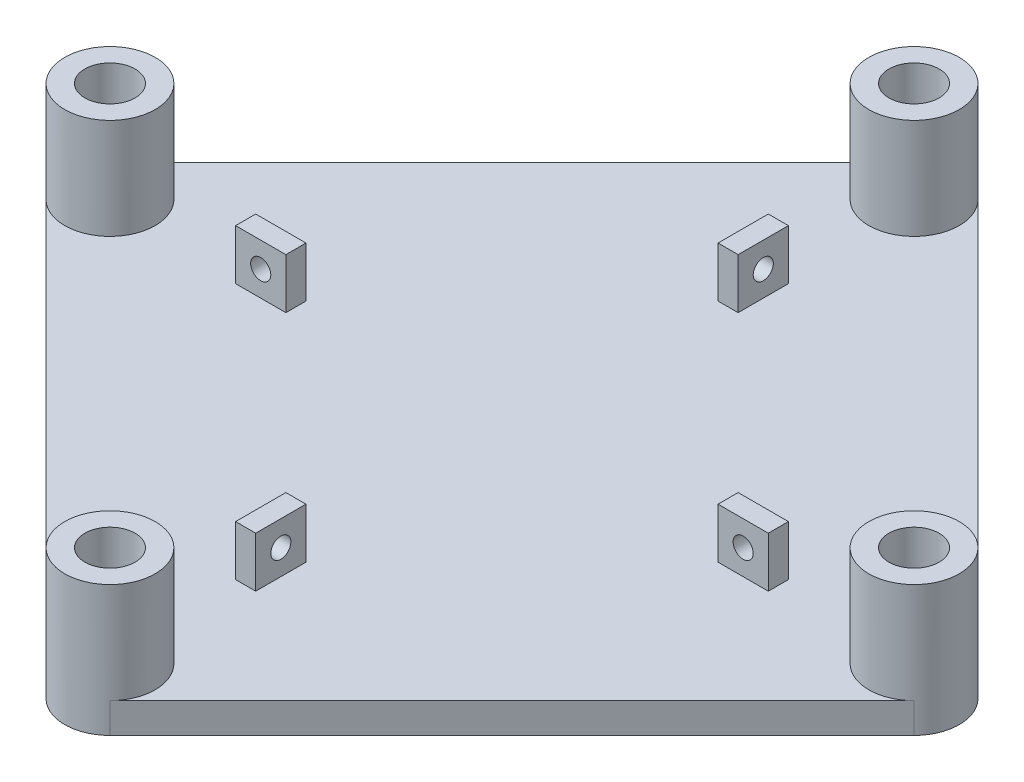
from build123d import *

# Parameters (mm, degrees)
SKETCH1_W           = 100
SKETCH1_H           = 100
BOSS_EXTRUDE1_DEPTH = 3
SKETCH2_R           = 4.5
SKETCH2_R_2         = 2.5
BOSS_EXTRUDE2_DEPTH = 10
SKETCH3_W           = 4.999999906
SKETCH3_H           = 2
SKETCH3_W_2         = 2
SKETCH3_H_2         = 4.999999906
BOSS_EXTRUDE3_DEPTH = 5
CUT_EXTRUDE1_REACH  = 74.595
SKETCH4_R           = 1
CUT_EXTRUDE2_REACH  = 74.595
SKETCH5_R           = 1
CUT_EXTRUDE3_REACH  = 74.595
SKETCH7_R           = 1
CUT_EXTRUDE4_REACH  = 74.595
SKETCH8_R           = 1
SKETCH9_OUTSIDE_W   = 130.404
SKETCH9_OUTSIDE_H   = 130.404
CUT_EXTRUDE5_DEPTH  = 127


with BuildPart() as part:
    # Sketch1 → Boss-Extrude1 (new body)
    with BuildSketch(Plane(origin=(0, 0, 0), x_dir=(1, 0, 0), z_dir=(0, 1, 0))):
        Rectangle(SKETCH1_W, SKETCH1_H)
    extrude(amount=BOSS_EXTRUDE1_DEPTH)

    # Sketch2 → Boss-Extrude2 (add)
    # profile 1 of 4: a face of its own
    with BuildSketch(Plane(origin=(0, 3, 0), x_dir=(1, 0, 0), z_dir=(0, 1, 0))):
        with Locations((0, 40)):
            Circle(SKETCH2_R)
        with Locations((0, 40)):
            Circle(SKETCH2_R_2, mode=Mode.SUBTRACT)
    # profile 2 of 4: a face of its own
    with BuildSketch(Plane(origin=(0, 3, 0), x_dir=(1, 0, 0), z_dir=(0, 1, 0))):
        with Locations((40, 0)):
            Circle(SKETCH2_R)
        with Locations((40, 0)):
            Circle(SKETCH2_R_2, mode=Mode.SUBTRACT)
    # profile 3 of 4: a face of its own
    with BuildSketch(Plane(origin=(0, 3, 0), x_dir=(1, 0, 0), z_dir=(0, 1, 0))):
        with Locations((0, -40)):
            Circle(SKETCH2_R)
        with Locations((0, -40)):
            Circle(SKETCH2_R_2, mode=Mode.SUBTRACT)
    # profile 4 of 4: a face of its own
    with BuildSketch(Plane(origin=(0, 3, 0), x_dir=(1, 0, 0), z_dir=(0, 1, 0))):
        with Locations((-40, 0)):
            Circle(SKETCH2_R)
        with Locations((-40, 0)):
            Circle(SKETCH2_R_2, mode=Mode.SUBTRACT)
    extrude(amount=BOSS_EXTRUDE2_DEPTH)

    # Sketch3 → Boss-Extrude3 (add)
    with BuildSketch(Plane(origin=(0, 3, 0), x_dir=(1, 0, 0), z_dir=(0, 1, 0))):
        with Locations((24.000000006, 0)):
            Rectangle(SKETCH3_W, SKETCH3_H)
        with Locations((0, 24.000000006)):
            Rectangle(SKETCH3_W_2, SKETCH3_H_2)
        with Locations((0, -24.000000006)):
            Rectangle(SKETCH3_W_2, SKETCH3_H_2)
        with Locations((-24.000000006, 0)):
            Rectangle(SKETCH3_W, SKETCH3_H)
    extrude(amount=BOSS_EXTRUDE3_DEPTH)

    # Sketch4 → Cut-Extrude1 (cut, up to next)
    with BuildSketch(Plane(origin=(1, 0, 0), x_dir=(0, 0, -1), z_dir=(1, 0, 0)), mode=Mode.PRIVATE) as cut_extrude1_sk1:
        with Locations((24.000000006, 5.5)):
            Circle(SKETCH4_R)
    cut_extrude1_tool1 = extrude(cut_extrude1_sk1.sketch, amount=-CUT_EXTRUDE1_REACH, mode=Mode.PRIVATE) & part.part
    add(cut_extrude1_tool1.solids().sort_by_distance((1, 5.5, -24))[0], mode=Mode.SUBTRACT)

    # Sketch5 → Cut-Extrude2 (cut, up to next)
    with BuildSketch(Plane(origin=(0, 0, -1), x_dir=(-1, 0, 0), z_dir=(0, 0, -1)), mode=Mode.PRIVATE) as cut_extrude2_sk1:
        with Locations((24.000000006, 5.5)):
            Circle(SKETCH5_R)
    cut_extrude2_tool1 = extrude(cut_extrude2_sk1.sketch, amount=-CUT_EXTRUDE2_REACH, mode=Mode.PRIVATE) & part.part
    add(cut_extrude2_tool1.solids().sort_by_distance((-24, 5.5, -1))[0], mode=Mode.SUBTRACT)

    # Sketch7 → Cut-Extrude3 (cut, up to next)
    with BuildSketch(Plane.ZY.offset(1), mode=Mode.PRIVATE) as cut_extrude3_sk1:
        with Locations((24.000000006, 5.5)):
            Circle(SKETCH7_R)
    cut_extrude3_tool1 = extrude(cut_extrude3_sk1.sketch, amount=-CUT_EXTRUDE3_REACH, mode=Mode.PRIVATE) & part.part
    add(cut_extrude3_tool1.solids().sort_by_distance((-1, 5.5, 24))[0], mode=Mode.SUBTRACT)

    # Sketch8 → Cut-Extrude4 (cut, up to next)
    with BuildSketch(Plane.XY.offset(1), mode=Mode.PRIVATE) as cut_extrude4_sk1:
        with Locations((24.000000006, 5.5)):
            Circle(SKETCH8_R)
    cut_extrude4_tool1 = extrude(cut_extrude4_sk1.sketch, amount=-CUT_EXTRUDE4_REACH, mode=Mode.PRIVATE) & part.part
    add(cut_extrude4_tool1.solids().sort_by_distance((24, 5.5, 1))[0], mode=Mode.SUBTRACT)

    # Sketch9 outside → Cut-Extrude5 (cut)
    with BuildSketch(Plane(origin=(0, 3, 0), x_dir=(1, 0, 0), z_dir=(0, 1, 0))):
        Rectangle(SKETCH9_OUTSIDE_W, SKETCH9_OUTSIDE_H)
        with BuildLine():
            Line((3.181980515, 43.181980515), (43.181980515, 3.181980515))
            ThreePointArc((43.181980515, 3.181980515), (44.5, 0), (43.181980515, -3.181980515))
            Line((43.181980515, -3.181980515), (3.181980515, -43.181980515))
            ThreePointArc((3.181980515, -43.181980515), (0, -44.5), (-3.181980515, -43.181980515))
            Line((-3.181980515, -43.181980515), (-43.181980515, -3.181980515))
            ThreePointArc((-43.181980515, -3.181980515), (-44.5, 0), (-43.181980515, 3.181980515))
            Line((-43.181980515, 3.181980515), (-3.181980515, 43.181980515))
            ThreePointArc((-3.181980515, 43.181980515), (0, 44.5), (3.181980515, 43.181980515))
        make_face(mode=Mode.SUBTRACT)
    extrude(amount=-CUT_EXTRUDE5_DEPTH, mode=Mode.SUBTRACT)


solid = part.part
